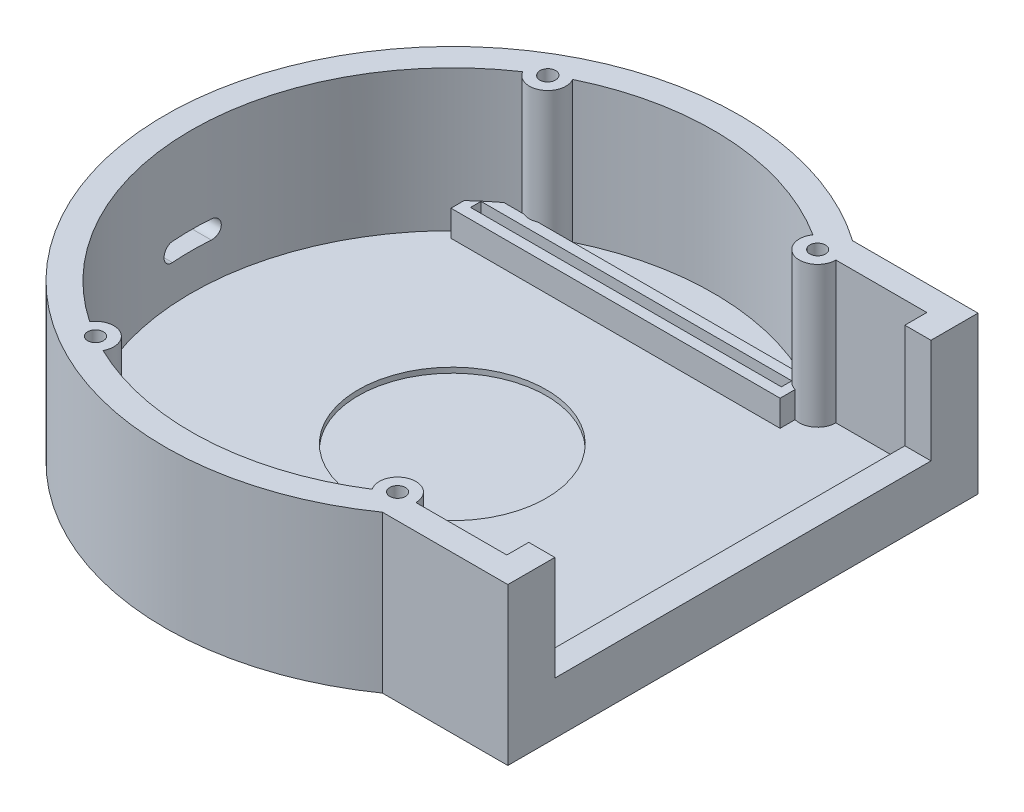
from build123d import *

# Parameters (mm, degrees)
SKETCH1_R               = 55
SKETCH1_W               = 30.631456328
SKETCH1_H               = 90
HOUSING_DEPTH           = 30
INTERNALCUT_DEPTH       = 27
SKETCH7_W               = 72
SKETCH7_H               = 25
DISPLAYCUT_DEPTH        = 27
SKETCH11_R              = 18
WICHARGERCUT_DEPTH      = 1
SKETCH14_W              = 4.6
SKETCH14_H              = 6.1
BTNINTERNALCUT_DEPTH    = 1
SKETCH16_R              = 1.5
BTNEXTERNALCUT_DEPTH    = 116.280995765
SKETCH18_R              = 6
BUZZEREXTERNALCUT_DEPTH = 1
SKETCH20_R              = 0.35
BUZZERINTERNALCUT_DEPTH = 116.863890151
SKETCH23_W              = 3.7
SKETCH23_H              = 8.5
SWITCHINTERNALCUT_DEPTH = 1
SKETCH25_W              = 1.7
SKETCH25_H              = 3.6
SWITCHEXTERNALCUT_DEPTH = 124.821406818
MICROUSBCUT_DEPTH       = 128.13897565
SKETCH29_R              = 3.5
SKETCH29_R_2            = 1.5
BOSS_EXTRUDE1_DEPTH     = 27
CUT_EXTRUDE1_DEPTH      = 83.757833161
CUT_EXTRUDE1_DEPTH_BACK = 83.757833161
SKETCH30_R              = 1.5
BOSS_EXTRUDE3_START     = 5
SKETCH31_W              = 59.5
SKETCH31_H              = 2
BOSS_EXTRUDE3_DEPTH     = 5


with BuildPart() as part:
    # Sketch1 → Housing (new body)
    with BuildSketch(Plane(origin=(0, 0, 0), x_dir=(1, 0, 0), z_dir=(0, 1, 0))):
        Circle(SKETCH1_R)
        with Locations((40.315728164, -0.0001724)):
            Rectangle(SKETCH1_W, SKETCH1_H)
    extrude(amount=HOUSING_DEPTH)

    # Sketch8 → InternalCut (cut)
    with BuildSketch(Plane(origin=(0, 30, 0), x_dir=(1, 0, 0), z_dir=(0, 1, 0))):
        with BuildLine():
            Line((29.73123171, -40.2001724), (50.631456328, -40.2001724))
            Line((50.631456328, -40.2001724), (50.631456328, 40.1998276))
            Line((50.631456328, 40.1998276), (29.731697916, 40.1998276))
            ThreePointArc((29.731697916, 40.1998276), (-49.999999999, 0.000289929), (29.73123171, -40.2001724))
        make_face()
    extrude(amount=-INTERNALCUT_DEPTH, mode=Mode.SUBTRACT)

    # Sketch7 → DisplayCut (cut)
    with BuildSketch(Plane(origin=(55.631456328, 0, 0), x_dir=(0, 0, -1), z_dir=(1, 0, 0))):
        with Locations((-0.0001724, 22.5)):
            Rectangle(SKETCH7_W, SKETCH7_H)
    extrude(amount=-DISPLAYCUT_DEPTH, mode=Mode.SUBTRACT)

    # Sketch11 → WiChargerCut (cut)
    with BuildSketch(Plane(origin=(0, 3, 0), x_dir=(1, 0, 0), z_dir=(0, 1, 0))):
        Circle(SKETCH11_R)
    extrude(amount=-WICHARGERCUT_DEPTH, mode=Mode.SUBTRACT)

    # Sketch14 → BtnInternalCut (cut)
    with BuildSketch(Plane(origin=(4.856972308, 3, -39.46084295), x_dir=(1, 0, 0), z_dir=(0, 1, 0))):
        with Locations((-0.204569722, -74.22253241)):
            Rectangle(SKETCH14_W, SKETCH14_H)
    extrude(amount=-BTNINTERNALCUT_DEPTH, mode=Mode.SUBTRACT)

    # Sketch16 → BtnExternalCut (cut, through all)
    with BuildSketch(Plane(origin=(4.856972308, 2, -39.46084295), x_dir=(1, 0, 0), z_dir=(0, 1, 0))):
        with Locations((-0.204569722, -74.22253241)):
            Circle(SKETCH16_R)
    extrude(amount=-BTNEXTERNALCUT_DEPTH, mode=Mode.SUBTRACT)

    # Sketch18 → BuzzerExternalCut (cut)
    with BuildSketch(Plane(origin=(12.790381818, 3, 34.693395374), x_dir=(1, 0, 0), z_dir=(0, 1, 0))):
        with Locations((-25.006618322, 0)):
            Circle(SKETCH18_R)
    extrude(amount=-BUZZEREXTERNALCUT_DEPTH, mode=Mode.SUBTRACT)

    # Sketch20 → BuzzerInternalCut (cut, through all)
    with BuildSketch(Plane(origin=(12.790381818, 2, 34.693395374), x_dir=(1, 0, 0), z_dir=(0, 1, 0))):
        with Locations((-26.042348329, 4.522315504)):
            Circle(SKETCH20_R)
        with Locations((-26.042348329, 3.020429056)):
            Circle(SKETCH20_R)
        with Locations((-26.042348329, 1.518542609)):
            Circle(SKETCH20_R)
        with Locations((-26.042348329, 0.016656161)):
            Circle(SKETCH20_R)
        with Locations((-26.042348329, -1.485230286)):
            Circle(SKETCH20_R)
        with Locations((-26.042348329, -2.987116733)):
            Circle(SKETCH20_R)
        with Locations((-26.042348329, -4.489003181)):
            Circle(SKETCH20_R)
        with Locations((-24.042348329, 4.522315504)):
            Circle(SKETCH20_R)
        with Locations((-24.042348329, 3.020429056)):
            Circle(SKETCH20_R)
        with Locations((-22.042348329, 3.020429056)):
            Circle(SKETCH20_R)
        with Locations((-28.042348329, 3.020429056)):
            Circle(SKETCH20_R)
        with Locations((-24.042348329, 1.518542609)):
            Circle(SKETCH20_R)
        with Locations((-22.042348329, 1.518542609)):
            Circle(SKETCH20_R)
        with Locations((-20.042348329, 1.518542609)):
            Circle(SKETCH20_R)
        with Locations((-28.042348329, 1.518542609)):
            Circle(SKETCH20_R)
        with Locations((-30.042348329, 1.518542609)):
            Circle(SKETCH20_R)
        with Locations((-24.042348329, 0.016656161)):
            Circle(SKETCH20_R)
        with Locations((-22.042348329, 0.016656161)):
            Circle(SKETCH20_R)
        with Locations((-20.042348329, 0.016656161)):
            Circle(SKETCH20_R)
        with Locations((-24.042348329, -1.485230286)):
            Circle(SKETCH20_R)
        with Locations((-22.042348329, -1.485230286)):
            Circle(SKETCH20_R)
        with Locations((-20.042348329, -1.485230286)):
            Circle(SKETCH20_R)
        with Locations((-24.042348329, -2.987116733)):
            Circle(SKETCH20_R)
        with Locations((-22.042348329, -2.987116733)):
            Circle(SKETCH20_R)
        with Locations((-24.042348329, -4.489003181)):
            Circle(SKETCH20_R)
        with Locations((-28.042348329, -2.987116733)):
            Circle(SKETCH20_R)
        with Locations((-28.042348329, -1.485230286)):
            Circle(SKETCH20_R)
        with Locations((-30.042348329, -1.485230286)):
            Circle(SKETCH20_R)
        with Locations((-28.042348329, 0.016656161)):
            Circle(SKETCH20_R)
        with Locations((-30.042348329, 0.016656161)):
            Circle(SKETCH20_R)
    extrude(amount=-BUZZERINTERNALCUT_DEPTH, mode=Mode.SUBTRACT)

    # Sketch23 → SwitchInternalCut (cut)
    with BuildSketch(Plane(origin=(-6.532000561, 3, 48.360753742), x_dir=(1, 0, 0), z_dir=(0, 1, 0))):
        with Locations((23.409044431, 13.599064282)):
            Rectangle(SKETCH23_W, SKETCH23_H)
    extrude(amount=-SWITCHINTERNALCUT_DEPTH, mode=Mode.SUBTRACT)

    # Sketch25 → SwitchExternalCut (cut, through all)
    with BuildSketch(Plane(origin=(-6.532000561, 2, 48.360753742), x_dir=(1, 0, 0), z_dir=(0, 1, 0))):
        with Locations((23.409044431, 13.599064282)):
            Rectangle(SKETCH25_W, SKETCH25_H)
    extrude(amount=-SWITCHEXTERNALCUT_DEPTH, mode=Mode.SUBTRACT)

    # Sketch28 → MicroUSBCut (cut, through all)
    with BuildSketch(Plane(origin=(55.631456328, 0, 0), x_dir=(0, 0, -1), z_dir=(1, 0, 0))):
        with BuildLine():
            Line((-3.7251724, 13.5), (3.7248276, 13.5))
            ThreePointArc((3.7248276, 13.5), (5.4748276, 11.75), (3.7248276, 10))
            Line((3.7248276, 10), (-3.7251724, 10))
            ThreePointArc((-3.7251724, 10), (-5.4751724, 11.75), (-3.7251724, 13.5))
        make_face()
    extrude(amount=-MICROUSBCUT_DEPTH, mode=Mode.SUBTRACT)

    # Sketch29 → Boss-Extrude1 (add)
    # profile 1 of 4: a face of its own
    with BuildSketch(Plane(origin=(0, 3, 0), x_dir=(1, 0, 0), z_dir=(0, 1, 0))):
        with Locations((-24.932520247, 43.184391828)):
            Circle(SKETCH29_R)
        with Locations((-24.932520247, 43.184391828)):
            Circle(SKETCH29_R_2, mode=Mode.SUBTRACT)
    # profile 2 of 4: a face of its own
    with BuildSketch(Plane(origin=(0, 3, 0), x_dir=(1, 0, 0), z_dir=(0, 1, 0))):
        with Locations((-25, -43.301270189)):
            Circle(SKETCH29_R)
        with Locations((-25, -43.301270189)):
            Circle(SKETCH29_R_2, mode=Mode.SUBTRACT)
    # profile 3 of 4: a face of its own
    with BuildSketch(Plane(origin=(0, 3, 0), x_dir=(1, 0, 0), z_dir=(0, 1, 0))):
        with Locations((29.731697916, 40.1998276)):
            Circle(SKETCH29_R)
        with Locations((29.731697916, 40.1998276)):
            Circle(SKETCH29_R_2, mode=Mode.SUBTRACT)
    # profile 4 of 4: a face of its own
    with BuildSketch(Plane(origin=(0, 3, 0), x_dir=(1, 0, 0), z_dir=(0, 1, 0))):
        with Locations((29.73123171, -40.2001724)):
            Circle(SKETCH29_R)
        with Locations((29.73123171, -40.2001724)):
            Circle(SKETCH29_R_2, mode=Mode.SUBTRACT)
    extrude(amount=BOSS_EXTRUDE1_DEPTH)

    # Sketch30 → Cut-Extrude1 (cut, two sides: drawn at the far end of the back side and taken through both)
    with BuildSketch(Plane(origin=(0, 3, 0), x_dir=(1, 0, 0), z_dir=(0, 1, 0)).offset(-CUT_EXTRUDE1_DEPTH_BACK)):
        with Locations((29.731697916, 40.1998276)):
            Circle(SKETCH30_R)
        with Locations((-25, -43.301270189)):
            Circle(SKETCH30_R)
        with Locations((29.73123171, -40.2001724)):
            Circle(SKETCH30_R)
        with Locations((-25, 43.301270189)):
            Circle(SKETCH30_R)
    extrude(amount=CUT_EXTRUDE1_DEPTH + CUT_EXTRUDE1_DEPTH_BACK, mode=Mode.SUBTRACT)

    # Sketch31 → Boss-Extrude3 (add)
    with BuildSketch(Plane(origin=(0, 3, 0), x_dir=(1, 0, 0), z_dir=(0, 1, 0)).offset(BOSS_EXTRUDE3_START)):
        with BuildLine():
            Line((-26.280928, 39.954562648), (-30.060487747, 39.954562648))
            ThreePointArc((-30.060487747, 39.954562648), (-32.181707413, 38.266665755), (-34.208331283, 36.466286771))
            Line((-34.208331283, 36.466286771), (-34.208331283, 33.954562648))
            Line((-34.208331283, 33.954562648), (28.791668717, 33.954562648))
            Line((28.791668717, 33.954562648), (28.791668717, 36.82842654))
            ThreePointArc((28.791668717, 36.82842654), (27.020136784, 37.98681241), (26.240302048, 39.954562648))
            Line((26.240302048, 39.954562648), (-23.584112493, 39.954562648))
            ThreePointArc((-23.584112493, 39.954562648), (-24.932520247, 39.684391828), (-26.280928, 39.954562648))
        make_face()
        with Locations((-2.708331283, 36.954562648)):
            Rectangle(SKETCH31_W, SKETCH31_H, mode=Mode.SUBTRACT)
    extrude(amount=-BOSS_EXTRUDE3_DEPTH)


solid = part.part
